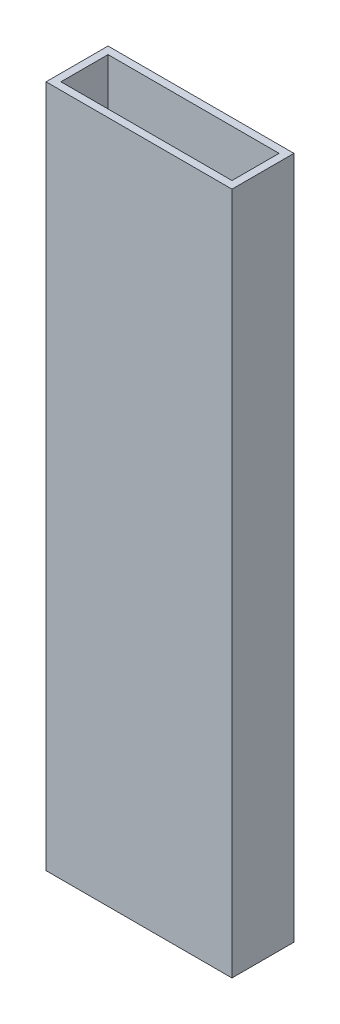
from build123d import *

# Parameters (mm, degrees)
SKETCH1_W           = 76.2
SKETCH1_H           = 25.4
SKETCH1_W_2         = 70.104
SKETCH1_H_2         = 19.304
BOSS_EXTRUDE1_DEPTH = 305.4
CUT_EXTRUDE1_START  = -12.7
SKETCH3_W           = 76.2
SKETCH3_H           = 25.4
CUT_EXTRUDE1_DEPTH  = 25.4
CUT_EXTRUDE2_START  = -12.7
SKETCH4_W           = 76.2
SKETCH4_H           = 25.4
CUT_EXTRUDE2_DEPTH  = 25.4


with BuildPart() as part:
    # Sketch1 → Boss-Extrude1 (new body)
    with BuildSketch(Plane(origin=(0, 0, 0), x_dir=(1, 0, 0), z_dir=(0, 1, 0))):
        Rectangle(SKETCH1_W, SKETCH1_H)
        Rectangle(SKETCH1_W_2, SKETCH1_H_2, mode=Mode.SUBTRACT)
    extrude(amount=BOSS_EXTRUDE1_DEPTH)

    # Sketch3 → Cut-Extrude1 (cut)
    with BuildSketch(Plane(origin=(0, 305.4, 0), x_dir=(1, 0, 0), z_dir=(0, 0, 1)).offset(CUT_EXTRUDE1_START)):
        Rectangle(SKETCH3_W, SKETCH3_H)
    extrude(amount=CUT_EXTRUDE1_DEPTH, mode=Mode.SUBTRACT)

    # Sketch4 → Cut-Extrude2 (cut)
    with BuildSketch(Plane.XY.offset(CUT_EXTRUDE2_START)):
        Rectangle(SKETCH4_W, SKETCH4_H)
    extrude(amount=CUT_EXTRUDE2_DEPTH, mode=Mode.SUBTRACT)


solid = part.part
